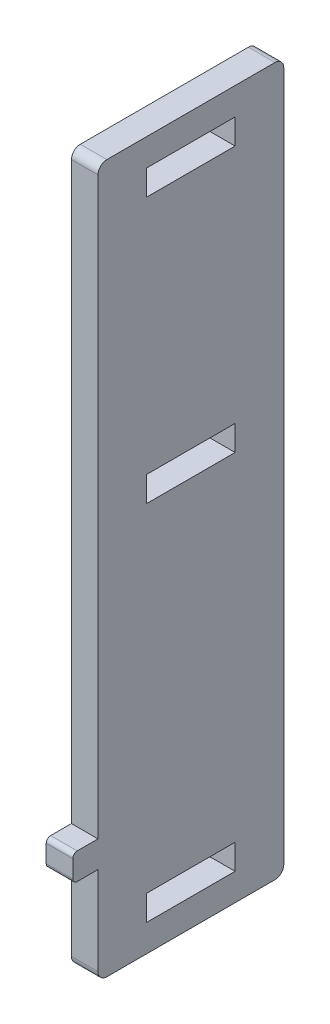
from build123d import *

# Parameters (mm, degrees)
SKETCH_1_W      = 10
SKETCH_1_H      = 2.85
EXTRUDE_1_DEPTH = 3
FILLET_1_R      = 1
FILLET_2_R      = 0.5


with BuildPart() as part:
    # Эскиз1 → Бобышка-Вытянуть1 (new body)
    with BuildSketch(Plane(origin=(0, 0, 0), x_dir=(0, 0, -1), z_dir=(1, 0, 0))):
        Polygon((-10.5, -40), (10.5, -40), (10.5, 40), (-10.5, 40), (-10.5, -26), (-13.35, -26), (-13.35, -29), (-10.5, -29), align=None)
        with Locations((0, 5.5)):
            Rectangle(SKETCH_1_W, SKETCH_1_H, mode=Mode.SUBTRACT)
        with Locations((0, -35.5)):
            Rectangle(SKETCH_1_W, SKETCH_1_H, mode=Mode.SUBTRACT)
        with Locations((0, 35.5)):
            Rectangle(SKETCH_1_W, SKETCH_1_H, mode=Mode.SUBTRACT)
    extrude(amount=EXTRUDE_1_DEPTH)

    # Скругление1
    fillet_1_edges = [part.edges().sort_by_distance(p)[0] for p in [
        (1.5, -40, -10.5),
        (1.5, -40, 10.5),
        (1.5, 40, 10.5),
        (1.5, 40, -10.5),
    ]]
    fillet(fillet_1_edges, radius=FILLET_1_R)

    # Скругление2
    fillet_2_edges = [part.edges().sort_by_distance(p)[0] for p in [
        (1.5, -29, 13.35),
        (1.5, -26, 13.35),
    ]]
    fillet(fillet_2_edges, radius=FILLET_2_R)


solid = part.part
